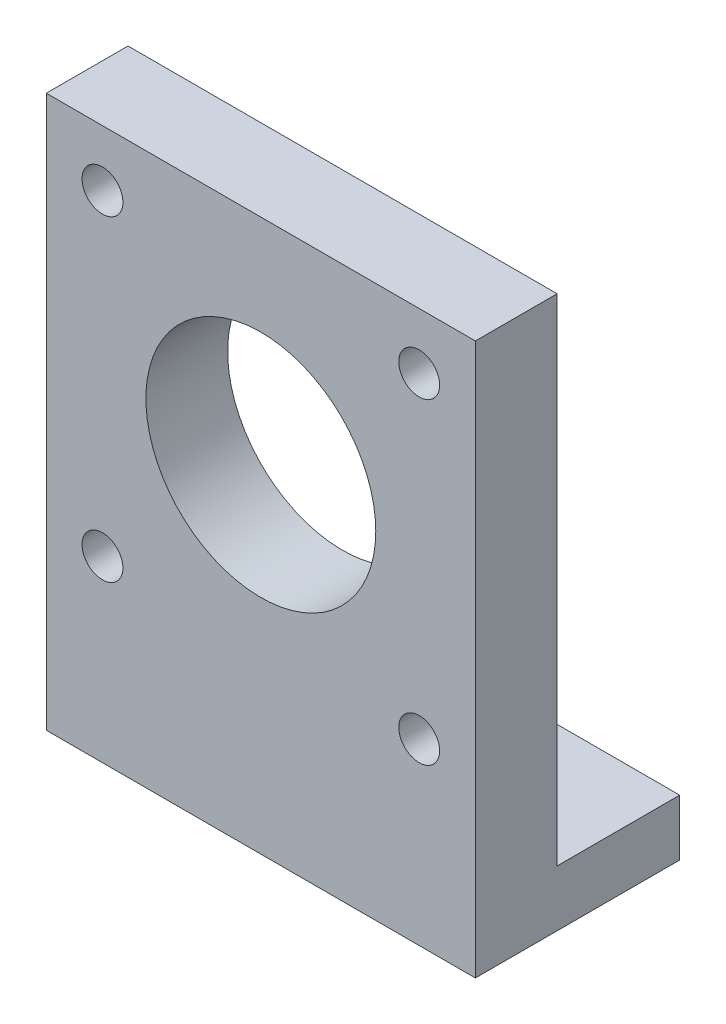
from build123d import *

# Parameters (mm, degrees)
ESQUISSE1_W        = 42
ESQUISSE1_H        = 42
ESQUISSE1_R        = 2
ESQUISSE1_R_2      = 11.25
BOSS_EXTRU_1_DEPTH = 8
ESQUISSE2_W        = 42
ESQUISSE2_H        = 12
BOSS_EXTRU_2_DEPTH = 8
ESQUISSE3_W        = 42
ESQUISSE3_H        = 5.5
BOSS_EXTRU_3_DEPTH = 12


with BuildPart() as part:
    # Esquisse1 → Boss.-Extru.1 (new body)
    with BuildSketch(Plane.XY):
        Rectangle(ESQUISSE1_W, ESQUISSE1_H)
        with Locations((-15.5, 15.5)):
            Circle(ESQUISSE1_R, mode=Mode.SUBTRACT)
        with Locations((15.5, 15.5)):
            Circle(ESQUISSE1_R, mode=Mode.SUBTRACT)
        with Locations((15.5, -15.5)):
            Circle(ESQUISSE1_R, mode=Mode.SUBTRACT)
        with Locations((-15.5, -15.5)):
            Circle(ESQUISSE1_R, mode=Mode.SUBTRACT)
        Circle(ESQUISSE1_R_2, mode=Mode.SUBTRACT)
    extrude(amount=BOSS_EXTRU_1_DEPTH)

    # Esquisse2 → Boss.-Extru.2 (add)
    with BuildSketch(Plane.XY.offset(8)):
        with Locations((0, -27)):
            Rectangle(ESQUISSE2_W, ESQUISSE2_H)
    extrude(amount=-BOSS_EXTRU_2_DEPTH)

    # Esquisse3 → Boss.-Extru.3 (add)
    with BuildSketch(Plane(origin=(0, 0, 0), x_dir=(-1, 0, 0), z_dir=(0, 0, -1))):
        with Locations((0, -30.25)):
            Rectangle(ESQUISSE3_W, ESQUISSE3_H)
    extrude(amount=BOSS_EXTRU_3_DEPTH)


solid = part.part
